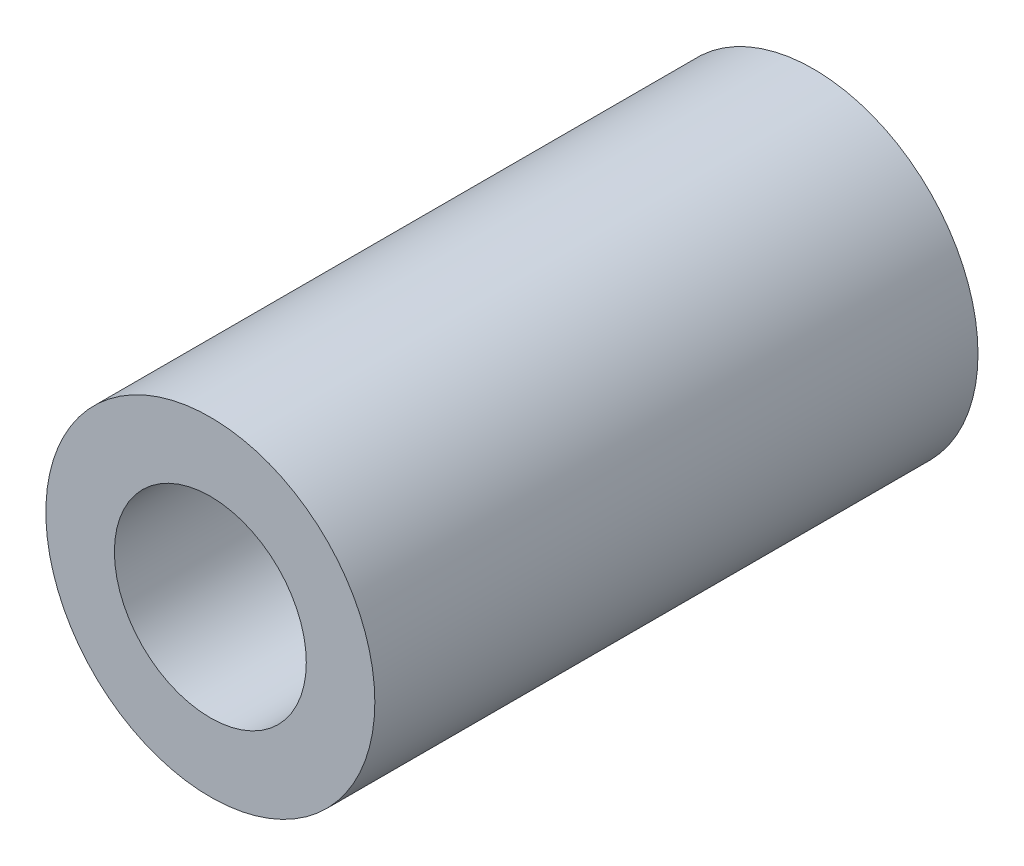
from build123d import *

# Parameters (mm, degrees)
SKETCH1_R           = 3
SKETCH1_R_2         = 1.75
BOSS_EXTRUDE1_DEPTH = 11


with BuildPart() as part:
    # Sketch1 → Boss-Extrude1 (new body)
    with BuildSketch(Plane.XY):
        Circle(SKETCH1_R)
        Circle(SKETCH1_R_2, mode=Mode.SUBTRACT)
    extrude(amount=BOSS_EXTRUDE1_DEPTH)


solid = part.part
